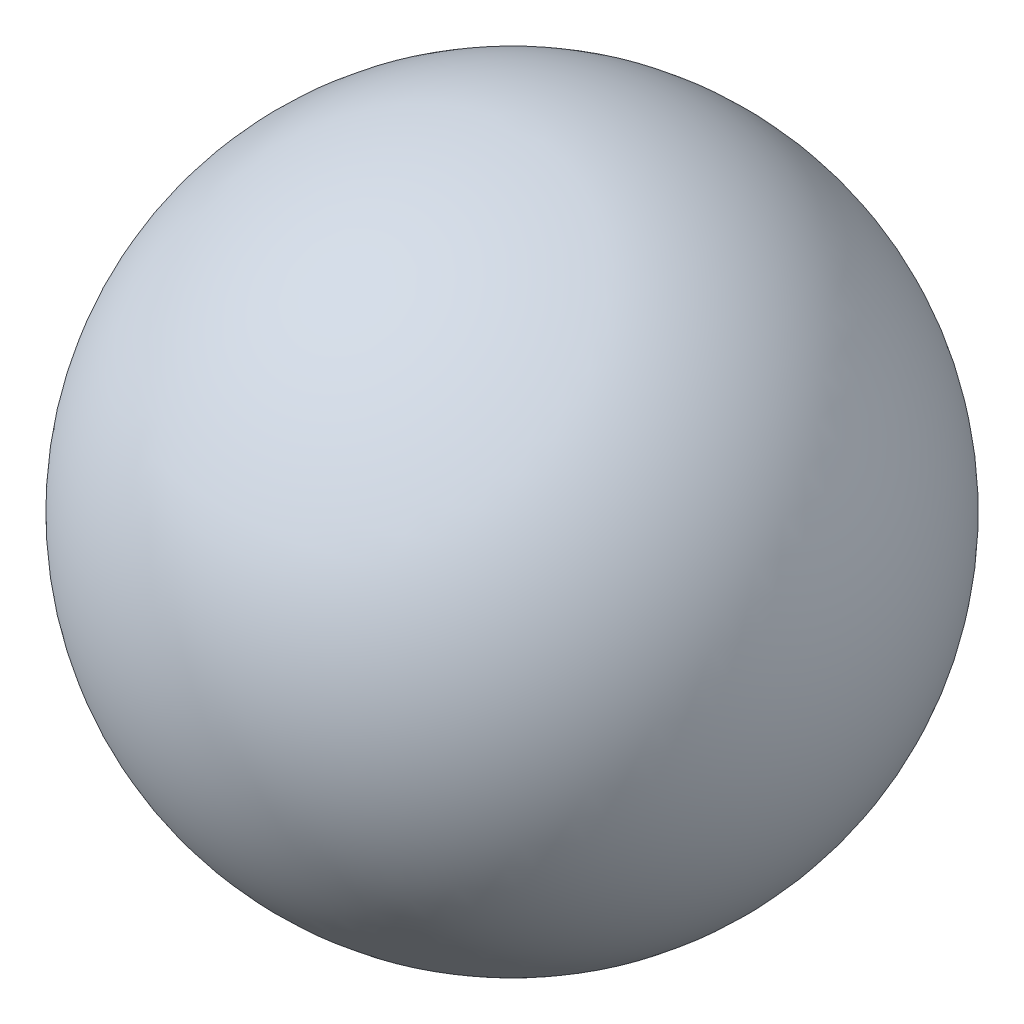
from build123d import *


with BuildPart() as part:
    # Croquis1 one side → Revolución2 (revolve)
    with BuildSketch(Plane.XY):
        with BuildLine():
            ThreePointArc((0, -15), (10.606601718, -10.606601718), (15, 0))
            ThreePointArc((15, 0), (10.606601718, 10.606601718), (0, 15))
            Line((0, 15), (0, -15))
        make_face()
    revolve(axis=Axis((0, 15, 0), (0, -1, 0)))


solid = part.part
